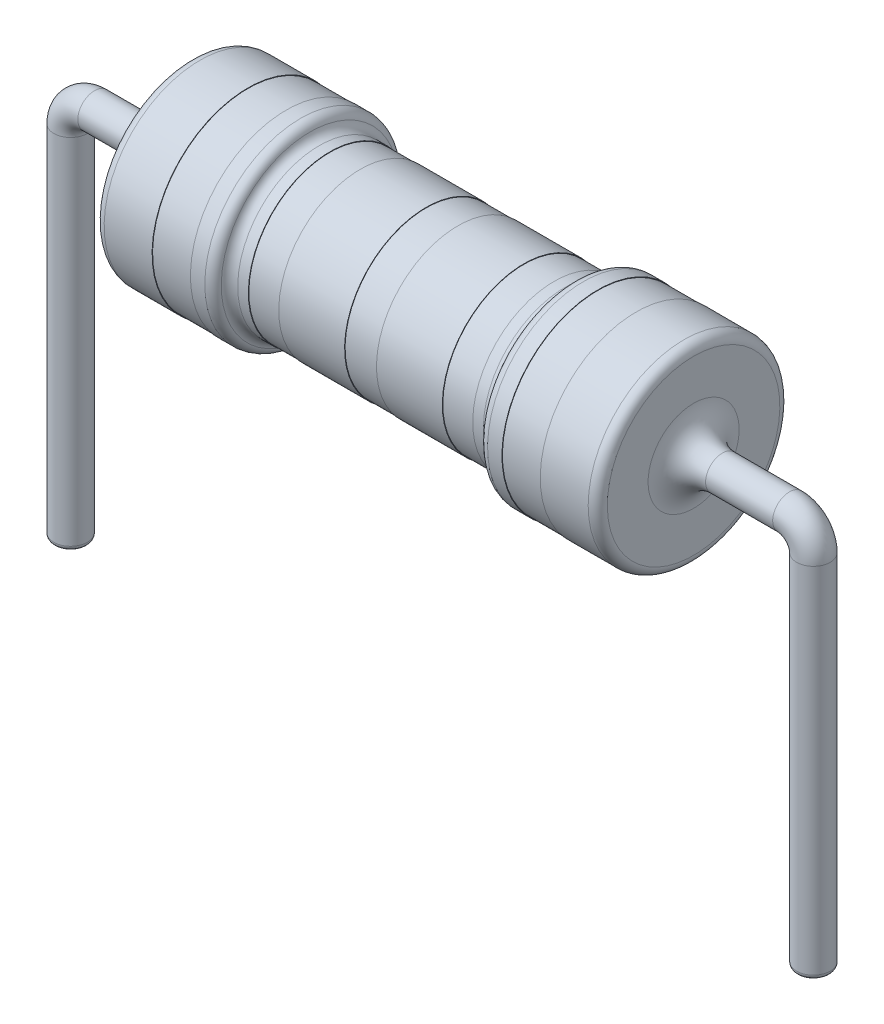
from build123d import *

# Parameters (mm, degrees)
FILLET2_R  = 0.2
FILLET3_R  = 0.2
FILLET4_R  = 0.2
FILLET5_R  = 0.2
FILLET6_R  = 0.2
SKETCH3_R  = 0.35
FILLET15_R = 0.1
FILLET16_R = 0.6


with BuildPart() as part:
    # Sketch1 → Revolve1 (revolve)
    with BuildSketch(Plane.XY):
        Polygon((-5.25, 0), (5.25, 0), (5.25, -2), (4.05, -2), (4.05, -1.99), (3.25, -1.99), (3.25, -2), (2.75, -2), (2.75, -1.7), (2.340690061, -1.7), (2.340690061, -1.69), (1.70680528, -1.69), (1.70680528, -1.7), (0.332543076, -1.7), (0.332543076, -1.69), (-0.332543076, -1.69), (-0.332543076, -1.7), (-1.70680528, -1.7), (-1.70680528, -1.69), (-2.340690061, -1.69), (-2.340690061, -1.7), (-2.75, -1.7), (-2.75, -2), (-3.25, -2), (-3.25, -1.99), (-4.05, -1.99), (-4.05, -2), (-5.25, -2), align=None)
    revolve(axis=Axis((-5.25, 0, 0), (1, 0, 0)))

    # Fillet2
    fillet2_edges = [part.edges().sort_by_distance(p)[0] for p in [
        (-2.75, 2, 0),
    ]]
    fillet(fillet2_edges, radius=FILLET2_R)

    # Fillet3
    fillet3_edges = [part.edges().sort_by_distance(p)[0] for p in [
        (-2.75, 1.7, 0),
        (2.75, 2, 0),
    ]]
    fillet(fillet3_edges, radius=FILLET3_R)

    # Fillet4
    fillet4_edges = [part.edges().sort_by_distance(p)[0] for p in [
        (2.75, 1.7, 0),
    ]]
    fillet(fillet4_edges, radius=FILLET4_R)

    # Fillet5
    fillet5_edges = [part.edges().sort_by_distance(p)[0] for p in [
        (-5.25, 2, 0),
    ]]
    fillet(fillet5_edges, radius=FILLET5_R)

    # Fillet6
    fillet6_edges = [part.edges().sort_by_distance(p)[0] for p in [
        (5.25, 2, 0),
    ]]
    fillet(fillet6_edges, radius=FILLET6_R)

    # Sweep4: sweep along a curve in space
    with BuildLine() as sweep4_path:
        Line((5.25, 0, 0), (7.25, 0, 0))
        ThreePointArc((7.75, -0.5, 0), (7.603553391, -0.146446609, 0), (7.25, 0, 0))
        Line((7.75, -0.5, 0), (7.75, -7.987172384, 0))
    # Sketch3 → Sweep4 (sweep)
    with BuildSketch(Plane(origin=(5.25, 0, 0), x_dir=(0, 0, -1), z_dir=(1, 0, 0))):
        Circle(SKETCH3_R)
    sweep4 = sweep(path=sweep4_path.line)

    # Mirror4: Sweep4 across plane
    add(sweep4.mirror(Plane(origin=(0, 0, 0), x_dir=(0, 0, 1), z_dir=(1, 0, 0))))

    # Fillet15
    fillet15_edges = [part.edges().sort_by_distance(p)[0] for p in [
        (7.75, -7.987172384, 0.35),
        (-7.75, -7.987172384, 0.35),
    ]]
    fillet(fillet15_edges, radius=FILLET15_R)

    # Fillet16
    fillet16_edges = [part.edges().sort_by_distance(p)[0] for p in [
        (5.25, 0, 0.35),
        (-5.25, 0, 0.35),
    ]]
    fillet(fillet16_edges, radius=FILLET16_R)


solid = part.part
